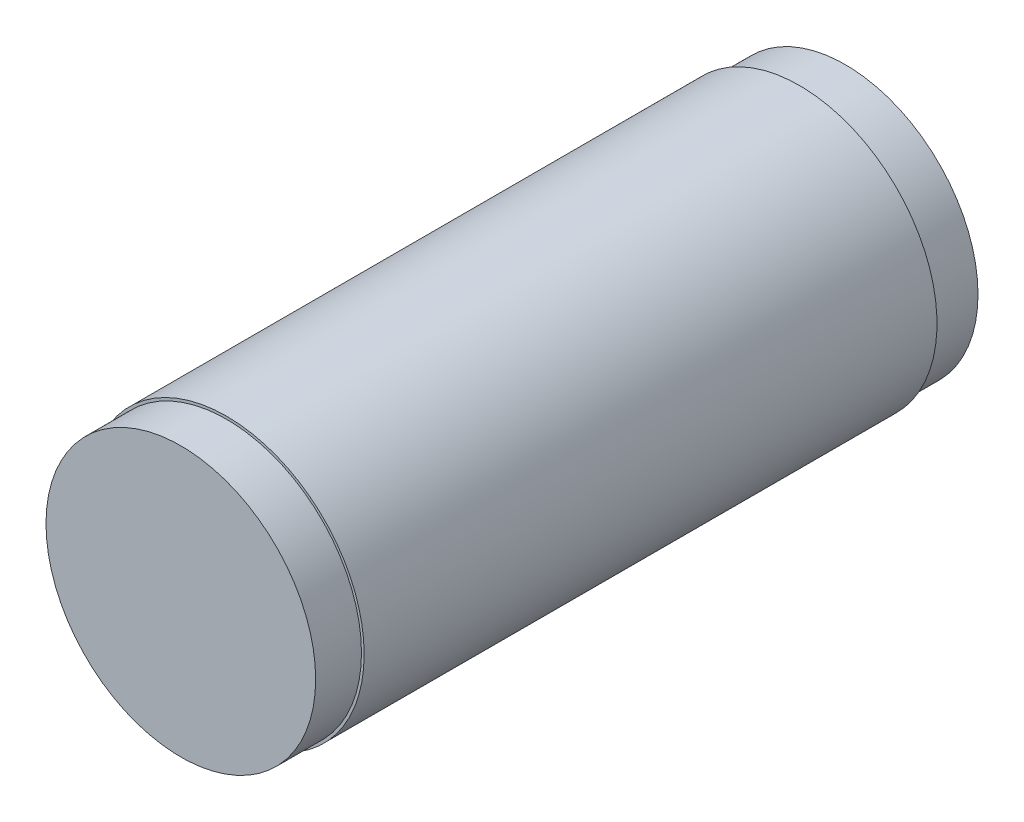
from build123d import *

# Parameters (mm, degrees)
SKETCH1_R           = 30
SKETCH1_R_2         = 25
BOSS_EXTRUDE1_DEPTH = 145
SKETCH2_R           = 25
BOSS_EXTRUDE2_DEPTH = 10
SKETCH3_R           = 25
BOSS_EXTRUDE3_DEPTH = 10
SKETCH11_R          = 30
SKETCH11_R_2        = 28.945980101
CUT_EXTRUDE2_DEPTH  = 10
SKETCH12_R          = 30
SKETCH12_R_2        = 29.420954363
CUT_EXTRUDE3_DEPTH  = 10


with BuildPart() as part:
    # Sketch1 → Boss-Extrude1 (new body)
    with BuildSketch(Plane.XY):
        Circle(SKETCH1_R)
        Circle(SKETCH1_R_2, mode=Mode.SUBTRACT)
    extrude(amount=BOSS_EXTRUDE1_DEPTH)

    # Sketch2 → Boss-Extrude2 (add)
    with BuildSketch(Plane.XY):
        Circle(SKETCH2_R)
    extrude(amount=BOSS_EXTRUDE2_DEPTH)

    # Sketch3 → Boss-Extrude3 (add)
    with BuildSketch(Plane.XY.offset(135)):
        Circle(SKETCH3_R)
    extrude(amount=BOSS_EXTRUDE3_DEPTH)

    # Sketch11 → Cut-Extrude2 (cut)
    with BuildSketch(Plane(origin=(0, 0, 0), x_dir=(-1, 0, 0), z_dir=(0, 0, -1))):
        Circle(SKETCH11_R)
        Circle(SKETCH11_R_2, mode=Mode.SUBTRACT)
    extrude(amount=-CUT_EXTRUDE2_DEPTH, mode=Mode.SUBTRACT)

    # Sketch12 → Cut-Extrude3 (cut)
    with BuildSketch(Plane.XY.offset(145)):
        Circle(SKETCH12_R)
        Circle(SKETCH12_R_2, mode=Mode.SUBTRACT)
    extrude(amount=-CUT_EXTRUDE3_DEPTH, mode=Mode.SUBTRACT)


solid = part.part
